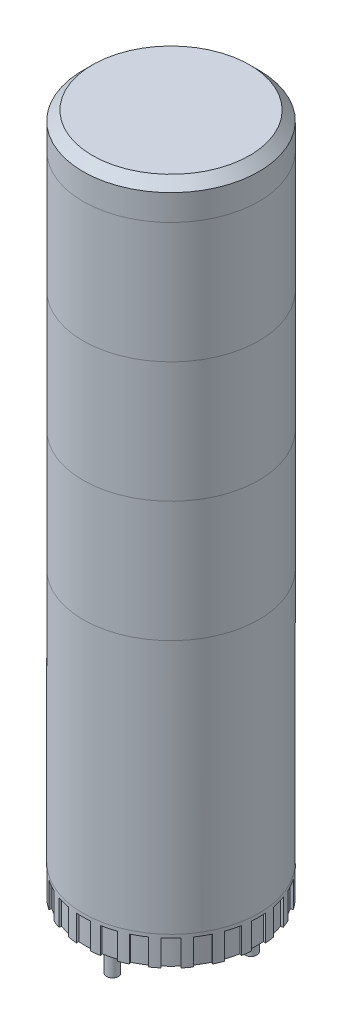
from build123d import *

# Parameters (mm, degrees)
SKETCH1_R          = 30
EXTRUDE1_DEPTH     = 232.4
CHAMFER1_SIZE      = 3.175
CUT_EXTRUDE1_DEPTH = 8.88
CIRPATTERN3_COUNT  = 24
SKETCH8_R          = 2
EXTRUDE2_DEPTH     = 12.7


with BuildPart() as part:
    # Sketch1 → Extrude1 (new body)
    with BuildSketch(Plane(origin=(0, 0, 0), x_dir=(1, 0, 0), z_dir=(0, 1, 0))):
        Circle(SKETCH1_R)
    extrude(amount=EXTRUDE1_DEPTH)

    # Chamfer1
    chamfer1_edges = [part.edges().sort_by_distance(p)[0] for p in [
        (-30, 232.4, 0),
    ]]
    chamfer(chamfer1_edges, length=CHAMFER1_SIZE)

    # Sketch7 → Cut-Extrude1 (cut)
    with BuildSketch(Plane.XZ):
        with BuildLine():
            Line((29.905344814, 2.38125), (29.109013853, 2.38125))
            ThreePointArc((29.109013853, 2.38125), (29.20625, 0), (29.109013853, -2.38125))
            Line((29.109013853, -2.38125), (29.905344814, -2.38125))
            ThreePointArc((29.905344814, -2.38125), (30, 0), (29.905344814, 2.38125))
        make_face()
    cut_extrude1 = extrude(amount=-CUT_EXTRUDE1_DEPTH, mode=Mode.SUBTRACT)

    # CirPattern3: Cut-Extrude1 ×24 about axis
    cirpattern3_axis = Axis((0, 0, 0), (0, 1, 0))
    for i in range(1, CIRPATTERN3_COUNT):
        add(cut_extrude1.rotate(cirpattern3_axis, i * 360 / CIRPATTERN3_COUNT), mode=Mode.SUBTRACT)

    # Sketch8 → Extrude2 (add)
    with BuildSketch(Plane.XZ):
        with Locations((0, 20)):
            Circle(SKETCH8_R)
        with Locations((17.320508076, -10)):
            Circle(SKETCH8_R)
        with Locations((-17.320508076, -10)):
            Circle(SKETCH8_R)
    extrude(amount=EXTRUDE2_DEPTH)


solid = part.part
